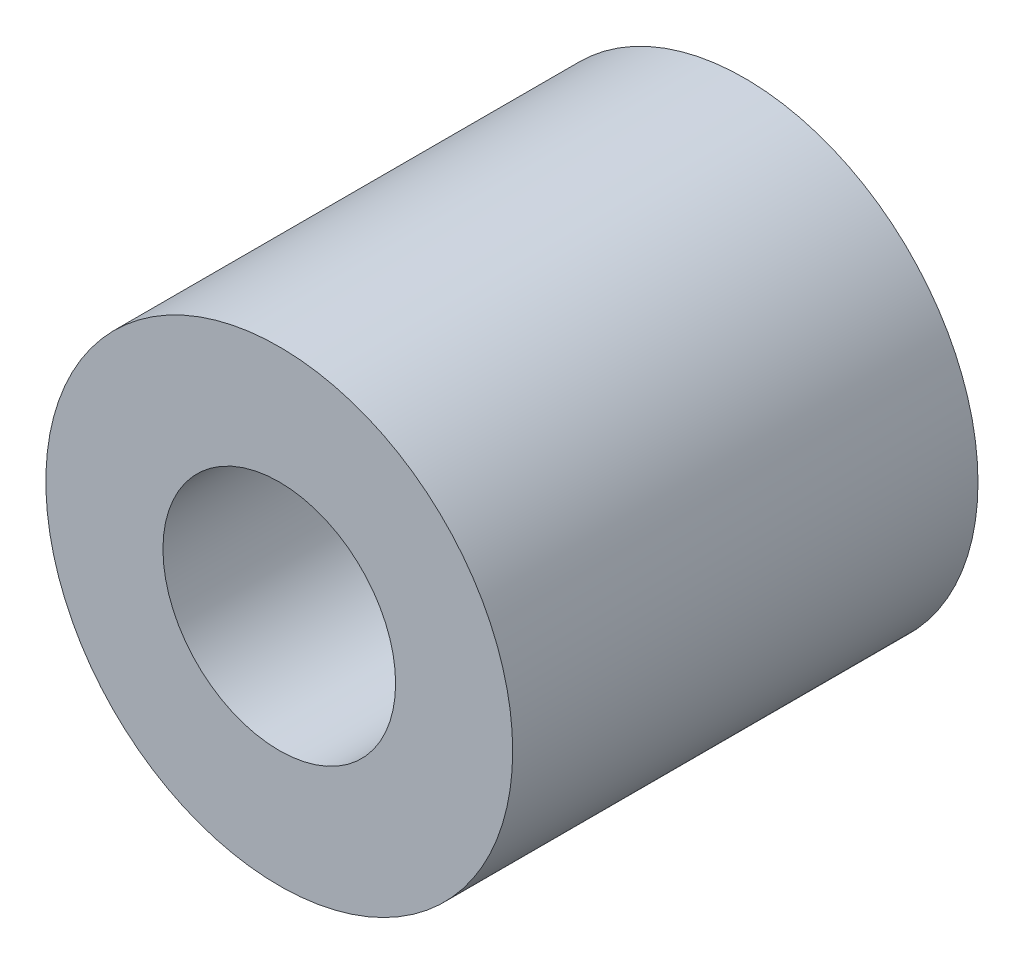
from build123d import *

# Parameters (mm, degrees)
SKETCH1_R      = 3.01
SKETCH1_R_2    = 1.5
EXTRUDE1_DEPTH = 3


with BuildPart() as part:
    # Sketch1 → Extrude1 (new body, symmetric)
    with BuildSketch(Plane.XY):
        Circle(SKETCH1_R)
        Circle(SKETCH1_R_2, mode=Mode.SUBTRACT)
    extrude(amount=EXTRUDE1_DEPTH, both=True)


solid = part.part
